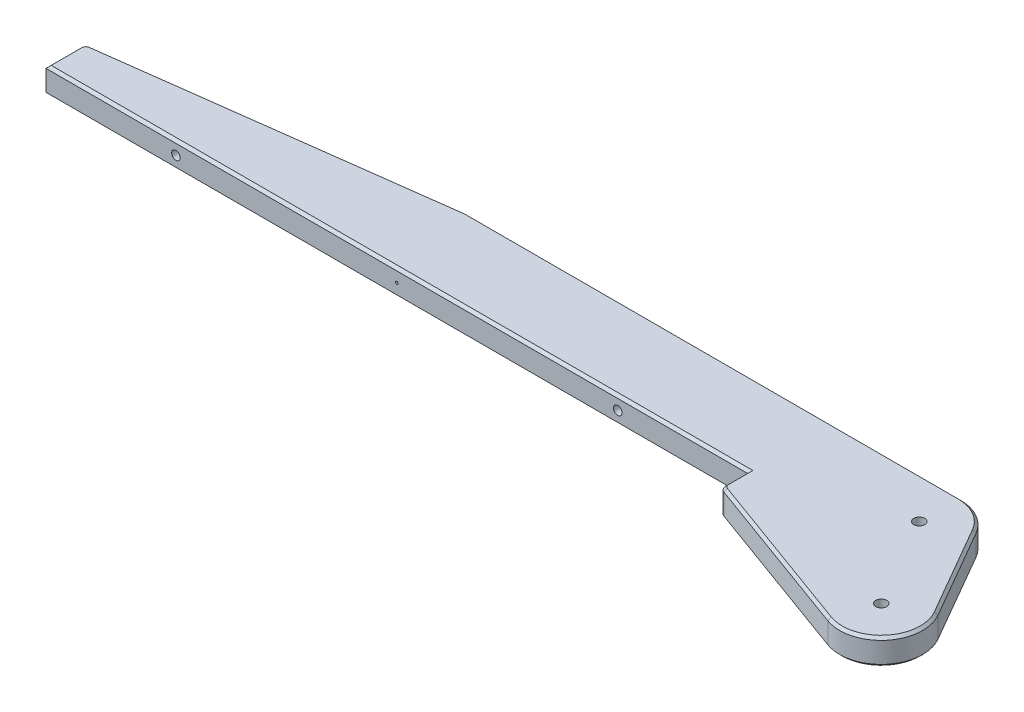
from build123d import *

# Parameters (mm, degrees)
BOSS_EXTRUDE1_DEPTH       = 5
M5X0_8_TAPPED_HOLE1_D     = 4.2
SKETCH14_R                = 4.15
CUT_EXTRUDE2_DEPTH        = 6
M4X0_7_TAPPED_HOLE1_D     = 3.3
M4X0_7_TAPPED_HOLE1_DEPTH = 15
M4X0_7_TAPPED_HOLE1_TIP   = 0.991420021
FILLET1_R                 = 2.5
CHAMFER1_SIZE             = 1
F_1_0MM_DOWEL_HOLE1_D     = 1
F_1_0MM_DOWEL_HOLE1_DEPTH = 5
F_1_0MM_DOWEL_HOLE1_TIP   = 0.30043031


with BuildPart() as part:
    # Sketch2 → Boss-Extrude1 (new body, symmetric)
    with BuildSketch(Plane(origin=(0, 0, 0), x_dir=(1, 0, 0), z_dir=(0, 1, 0))):
        with BuildLine():
            Line((-210, 50.641016151), (-20, 50.641016151))
            ThreePointArc((-20, 50.641016151), (-12, 48.497422612), (-6.143593539, 42.641016151))
            Line((-6.143593539, 42.641016151), (13.856406461, 8))
            ThreePointArc((13.856406461, 8), (12.25671109, -10.284601755), (-5.472322293, -15.035081933))
            Line((-5.472322293, -15.035081933), (-70, 8.451072039))
            Line((-70, 8.451072039), (-70, 18.641016151))
            Line((-70, 18.641016151), (-340, 18.641016151))
            Line((-340, 18.641016151), (-340, 33.641016151))
            Line((-340, 33.641016151), (-210, 50.641016151))
        make_face()
    extrude(amount=BOSS_EXTRUDE1_DEPTH, both=True)

    # M5x0.8 Tapped Hole1 (through all)
    with Locations(Plane(origin=(0, 5, 0), x_dir=(1, 0, 0), z_dir=(0, 1, 0))):
        with Locations((-20, 34.641016151), (0, 0)):
            Hole(M5X0_8_TAPPED_HOLE1_D / 2)

    # Sketch14 → Cut-Extrude2 (cut)
    with BuildSketch(Plane.XZ.offset(5)):
        Circle(SKETCH14_R)
    extrude(amount=-CUT_EXTRUDE2_DEPTH, mode=Mode.SUBTRACT)

    # M4x0.7 Tapped Hole1
    with Locations(Plane.XY.offset(-18.641016151)):
        with Locations((-290, 0), (-120, 0)):
            Hole(M4X0_7_TAPPED_HOLE1_D / 2, depth=M4X0_7_TAPPED_HOLE1_DEPTH)
            with Locations((0, 0, -(M4X0_7_TAPPED_HOLE1_DEPTH + M4X0_7_TAPPED_HOLE1_TIP / 2))):  # 118° drill point
                Cone(0, M4X0_7_TAPPED_HOLE1_D / 2, M4X0_7_TAPPED_HOLE1_TIP, mode=Mode.SUBTRACT)

    # Fillet1
    fillet1_edges = [part.edges().sort_by_distance(p)[0] for p in [
        (-70, 0, -8.451072039),
        (-340, 0, -33.641016151),
        (-210, 0, -50.641016151),
    ]]
    fillet(fillet1_edges, radius=FILLET1_R)

    # Chamfer1
    chamfer1_edges = [part.edges().sort_by_distance(p)[0] for p in [
        (-70, -5, -14.421303518),
        (-205, -5, -18.641016151),
        (-114.918615686, -5, -50.641016151),
        (-12, -5, -48.497422612),
        (-205, 5, -18.641016151),
        (-70, 5, -14.421303518),
        (12.25671109, 5, 10.284601755),
        (3.856406461, 5, -25.320508076),
        (-12, 5, -48.497422612),
        (-273.992778821, -5, -42.27272969),
        (-273.992778821, 5, -42.27272969),
        (-36.913686326, -5, 3.5913613),
        (-340, -5, -25.043835126),
        (-69.547880111, -5, -8.767649794),
        (-339.37888369, -5, -33.095834527),
        (-209.999656106, -5, -50.635734213),
        (-340, 5, -25.043835126),
        (-36.913686326, 5, 3.5913613),
        (-69.547880111, 5, -8.767649794),
        (-339.37888369, 5, -33.095834527),
        (-209.999656106, 5, -50.635734213),
        (-114.918615686, 5, -50.641016151),
        (3.856406461, -5, -25.320508076),
        (12.25671109, -5, 10.284601755),
    ]]
    chamfer(chamfer1_edges, length=CHAMFER1_SIZE)

    # Ø1.0mm Dowel Hole1
    with Locations(Plane.XY.offset(-18.641016151)):
        with Locations((-205, 0)):
            Hole(F_1_0MM_DOWEL_HOLE1_D / 2, depth=F_1_0MM_DOWEL_HOLE1_DEPTH)
            with Locations((0, 0, -(F_1_0MM_DOWEL_HOLE1_DEPTH + F_1_0MM_DOWEL_HOLE1_TIP / 2))):  # 118° drill point
                Cone(0, F_1_0MM_DOWEL_HOLE1_D / 2, F_1_0MM_DOWEL_HOLE1_TIP, mode=Mode.SUBTRACT)


solid = part.part
